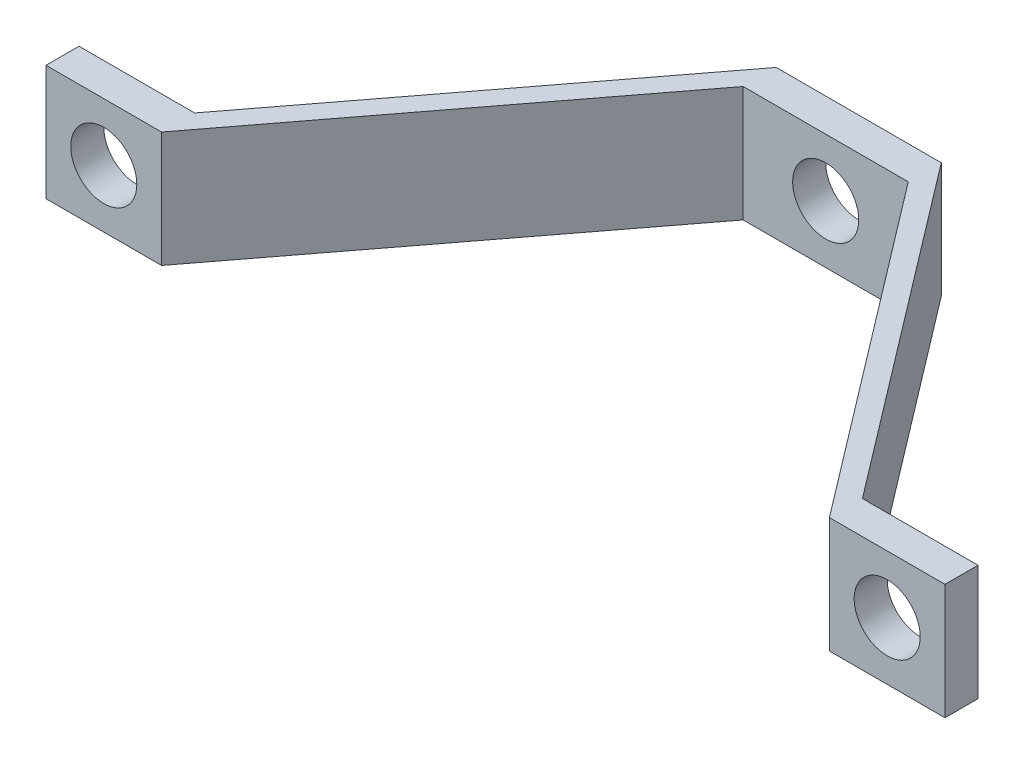
from build123d import *

# Parameters (mm, degrees)
BOSS_EXTRUDE1_DEPTH = 8.89
SKETCH2_R           = 2.54
CUT_EXTRUDE1_DEPTH  = 28.94
SKETCH3_R           = 2.54
CUT_EXTRUDE2_DEPTH  = 28.94
SKETCH4_R           = 2.54
CUT_EXTRUDE3_DEPTH  = 8.89


with BuildPart() as part:
    # Sketch1 → Boss-Extrude1 (new body)
    with BuildSketch(Plane(origin=(0, 0, 0), x_dir=(1, 0, 0), z_dir=(0, 1, 0))):
        Polygon((6.35, 0), (-6.35, 0), (-25.68448, -25.4), (-34.57448, -25.4), (-34.57448, -27.94), (-25.68448, -27.94), (-6.35, -2.54), (6.35, -2.54), (25.68448, -27.94), (34.57448, -27.94), (34.57448, -25.4), (25.68448, -25.4), align=None)
    extrude(amount=BOSS_EXTRUDE1_DEPTH)

    # Sketch2 → Cut-Extrude1 (cut, through all)
    with BuildSketch(Plane.XY.offset(27.94)):
        with Locations((-30.12948, 4.445)):
            Circle(SKETCH2_R)
    extrude(amount=-CUT_EXTRUDE1_DEPTH, mode=Mode.SUBTRACT)

    # Sketch3 → Cut-Extrude2 (cut, through all)
    with BuildSketch(Plane.XY.offset(27.94)):
        with Locations((30.12948, 4.445)):
            Circle(SKETCH3_R)
    extrude(amount=-CUT_EXTRUDE2_DEPTH, mode=Mode.SUBTRACT)

    # Sketch4 → Cut-Extrude3 (cut)
    with BuildSketch(Plane.XY.offset(2.54)):
        with Locations((0, 4.445)):
            Circle(SKETCH4_R)
    extrude(amount=-CUT_EXTRUDE3_DEPTH, mode=Mode.SUBTRACT)


solid = part.part
